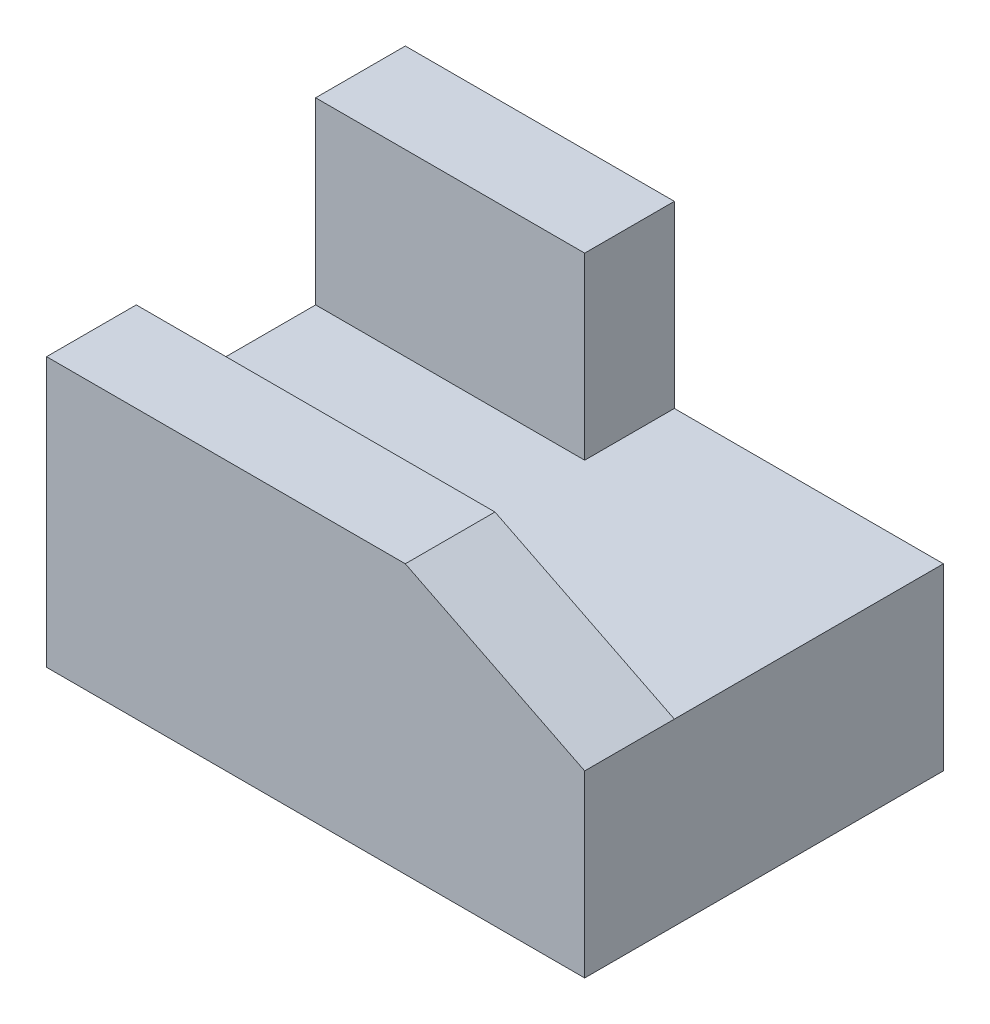
from build123d import *

# Parameters (mm, degrees)
SKETCH_1_W          = 30
SKETCH_1_H          = 20
EXTRUDE_1_DEPTH     = 10
SKETCH_1_3_W        = 30
SKETCH_1_3_H        = 5
EXTRUDE_2_DEPTH     = 15
SKETCH_1_4_W        = 15
SKETCH_1_4_H        = 5
EXTRUDE_3_DEPTH     = 20
CUT_EXTRUDE_1_DEPTH = 20
SCALE_1_SCALE       = 0.2


with BuildPart() as part:
    # 草圖1 → 填料-伸長1 (new body)
    with BuildSketch(Plane(origin=(0, 0, 0), x_dir=(1, 0, 0), z_dir=(0, 1, 0))):
        Rectangle(SKETCH_1_W, SKETCH_1_H)
    extrude(amount=EXTRUDE_1_DEPTH)

    # 草圖1<3> → 填料-伸長2 (add)
    with BuildSketch(Plane(origin=(0, 0, 0), x_dir=(1, 0, 0), z_dir=(0, 1, 0))):
        with Locations((0, -7.5)):
            Rectangle(SKETCH_1_3_W, SKETCH_1_3_H)
    extrude(amount=EXTRUDE_2_DEPTH)

    # 草圖1<4> → 填料-伸長3 (add)
    with BuildSketch(Plane(origin=(0, 0, 0), x_dir=(1, 0, 0), z_dir=(0, 1, 0))):
        with Locations((-7.5, 7.5)):
            Rectangle(SKETCH_1_4_W, SKETCH_1_4_H)
    extrude(amount=EXTRUDE_3_DEPTH)

    # 草圖2 → 除料-伸長1 (cut)
    with BuildSketch(Plane.XY.offset(10)):
        Polygon((5, 15), (15, 10), (15, 15), align=None)
    extrude(amount=-CUT_EXTRUDE_1_DEPTH, mode=Mode.SUBTRACT)


with BuildPart() as part_1:
    # 縮放比例1: scaled about (-0.960451977, 6.638418079, -0.127118644)
    add(part.part.scale(SCALE_1_SCALE).moved(Location((-0.768361582, 5.310734463, -0.101694915))))


solid = part_1.part
